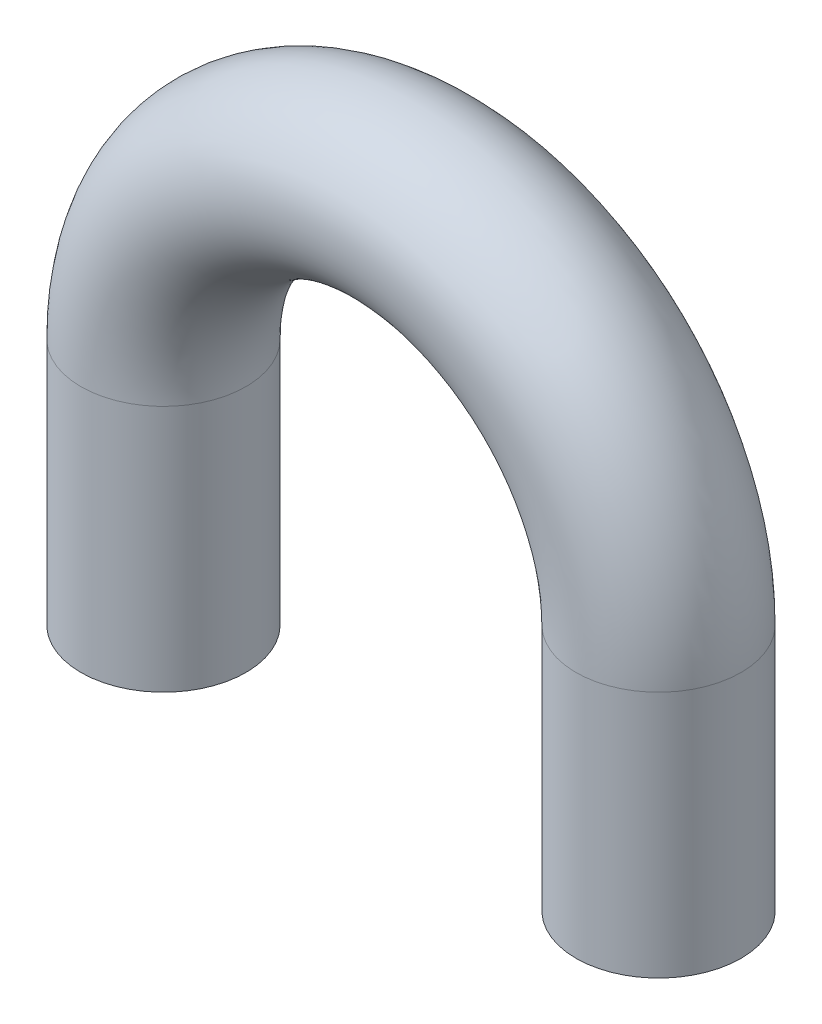
from build123d import *

# Parameters (mm, degrees)
ESQUISSE3_R = 1


with BuildPart() as part:
    # Balayage1: sweep along a path in Esquisse1
    with BuildLine(Plane.XY) as balayage1_path:
        Line((-3, 0), (-3, 3))
        ThreePointArc((-3, 3), (0, 6), (3, 3))
        Line((3, 3), (3, 0))
    # Esquisse3 → Balayage1 (sweep)
    with BuildSketch(Plane(origin=(0, 0, 0), x_dir=(1, 0, 0), z_dir=(0, 1, 0))):
        with Locations((3, 0)):
            Circle(ESQUISSE3_R)
    sweep(path=balayage1_path.line)


solid = part.part
